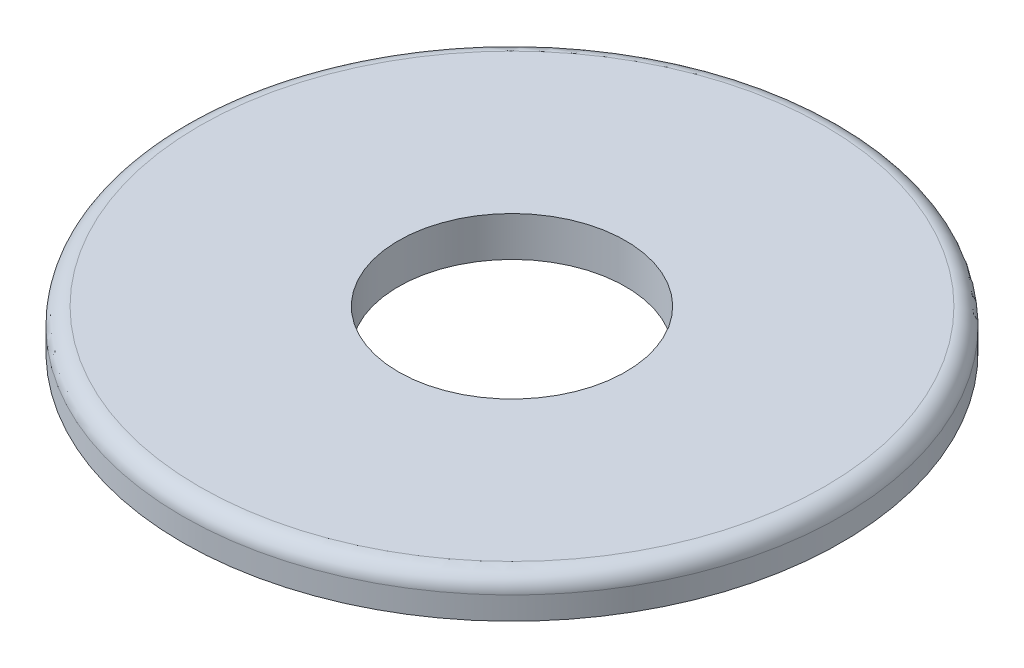
from build123d import *

# Parameters (mm, degrees)
SKETCH1_R           = 184.15
SKETCH1_R_2         = 63.5
BOSS_EXTRUDE1_DEPTH = 22.225
FILLET1_R           = 9.525


with BuildPart() as part:
    # Sketch1 → Boss-Extrude1 (new body)
    with BuildSketch(Plane(origin=(0, 0, 0), x_dir=(1, 0, 0), z_dir=(0, 1, 0))):
        Circle(SKETCH1_R)
        Circle(SKETCH1_R_2, mode=Mode.SUBTRACT)
    extrude(amount=BOSS_EXTRUDE1_DEPTH)

    # Fillet1
    fillet1_edges = [part.edges().sort_by_distance(p)[0] for p in [
        (-184.15, 22.225, 0),
    ]]
    fillet(fillet1_edges, radius=FILLET1_R)


solid = part.part
